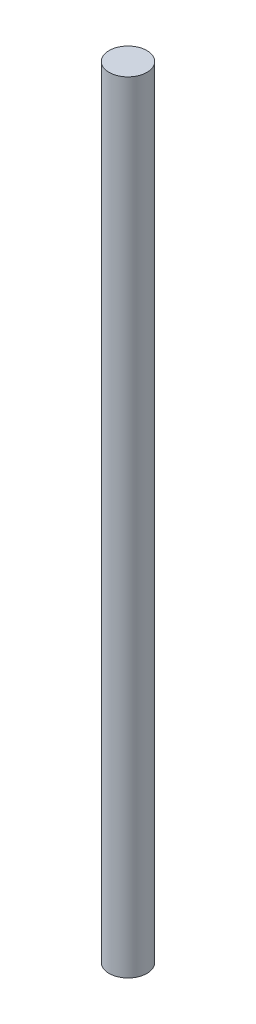
from build123d import *

# Parameters (mm, degrees)
SKETCH1_R           = 4
BOSS_EXTRUDE1_DEPTH = 165


with BuildPart() as part:
    # Sketch1 → Boss-Extrude1 (new body)
    with BuildSketch(Plane(origin=(0, 0, 0), x_dir=(1, 0, 0), z_dir=(0, 1, 0))):
        Circle(SKETCH1_R)
    extrude(amount=BOSS_EXTRUDE1_DEPTH)


solid = part.part
